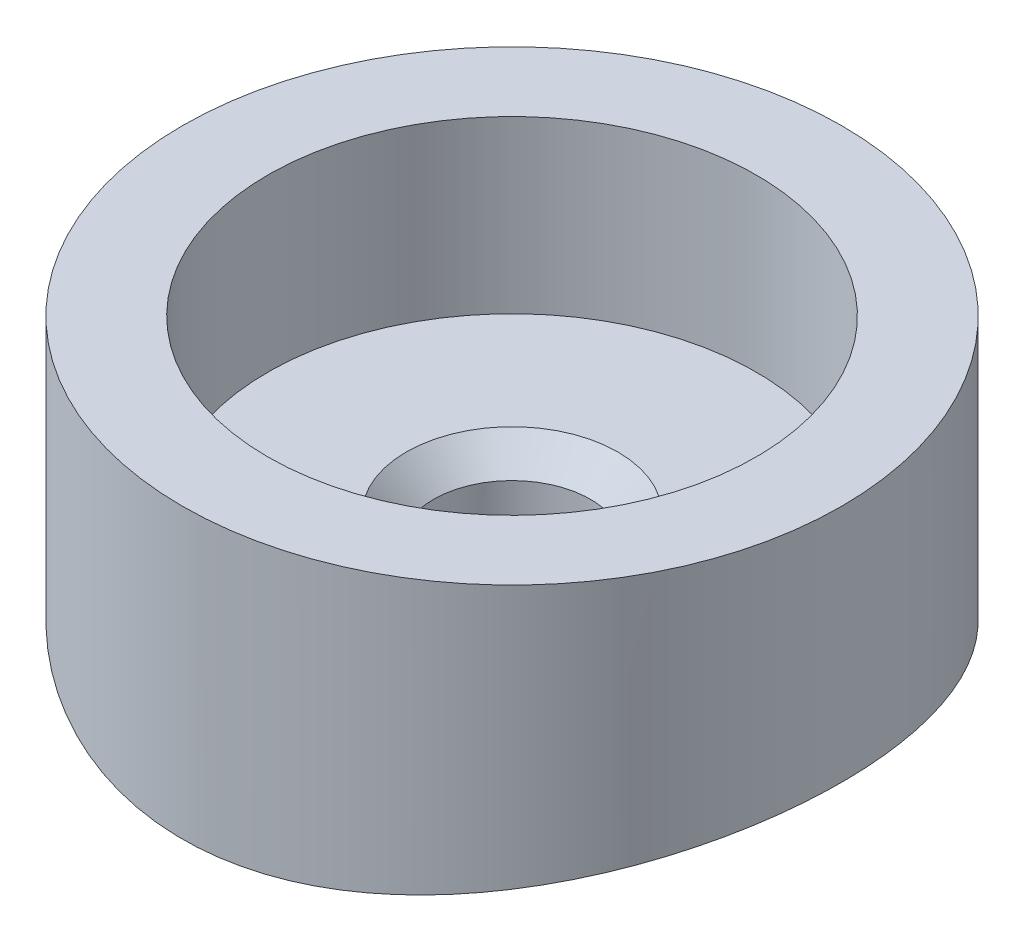
from build123d import *

# Parameters (mm, degrees)
SKETCH2_R               = 24.511
BOSS_EXTRUDE2_DEPTH     = 25.4
SKETCH3_R               = 18.161
CUT_EXTRUDE1_DEPTH      = 12.7
SKETCH11_R              = 83.82
CUT_EXTRUDE2_DEPTH      = 41.402
CUT_EXTRUDE2_DEPTH_BACK = 42.926
SKETCH13_R              = 5.842
CUT_EXTRUDE3_DEPTH      = 42.926
CHAMFER1_SIZE           = 2.032


with BuildPart() as part:
    # Sketch2 → Boss-Extrude2 (new body)
    with BuildSketch(Plane(origin=(0, 0, 0), x_dir=(1, 0, 0), z_dir=(0, 1, 0))):
        Circle(SKETCH2_R)
    extrude(amount=BOSS_EXTRUDE2_DEPTH)

    # Sketch3 → Cut-Extrude1 (cut)
    with BuildSketch(Plane(origin=(0, 25.4, 0), x_dir=(1, 0, 0), z_dir=(0, 1, 0))):
        Circle(SKETCH3_R)
    extrude(amount=-CUT_EXTRUDE1_DEPTH, mode=Mode.SUBTRACT)

    # Sketch11 → Cut-Extrude2 (cut, two sides)
    with BuildSketch(Plane(origin=(0, 0, 0), x_dir=(0, 0, -1), z_dir=(1, 0, 0))) as cut_extrude2_sk:
        with Locations((0, -76.2)):
            Circle(SKETCH11_R)
    extrude(amount=CUT_EXTRUDE2_DEPTH, mode=Mode.SUBTRACT)
    extrude(cut_extrude2_sk.sketch, amount=-CUT_EXTRUDE2_DEPTH_BACK, mode=Mode.SUBTRACT)

    # Sketch13 → Cut-Extrude3 (cut)
    with BuildSketch(Plane(origin=(0, 12.7, 0), x_dir=(1, 0, 0), z_dir=(0, 1, 0))):
        Circle(SKETCH13_R)
    extrude(amount=-CUT_EXTRUDE3_DEPTH, mode=Mode.SUBTRACT)

    # Chamfer1
    chamfer1_edges = [part.edges().sort_by_distance(p)[0] for p in [
        (-5.842, 12.7, 0),
    ]]
    chamfer(chamfer1_edges, length=CHAMFER1_SIZE)


solid = part.part
